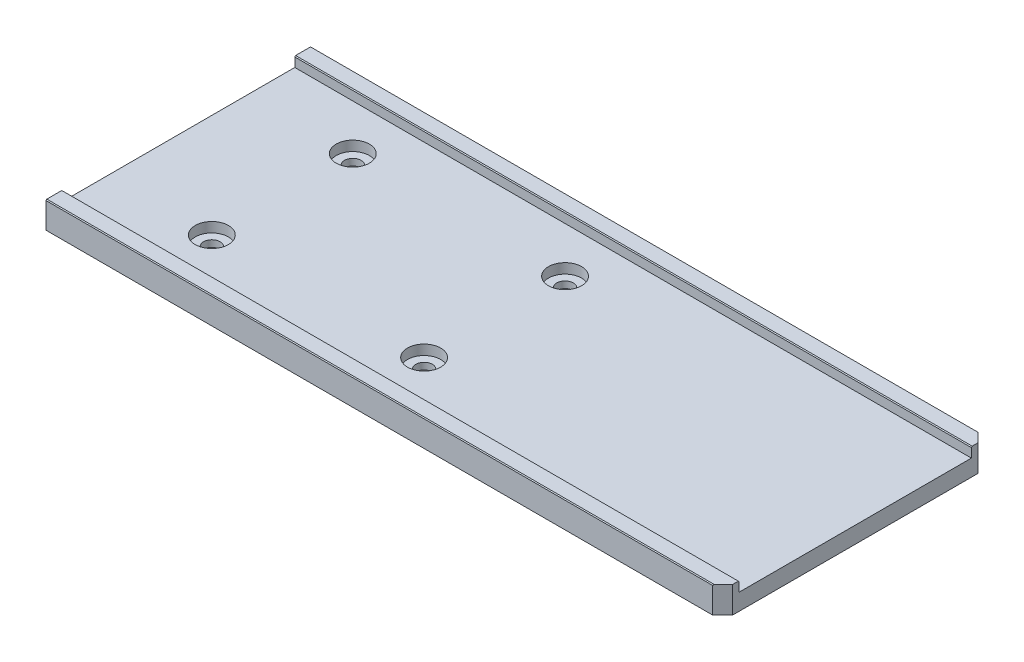
from build123d import *

# Parameters (mm, degrees)
SKETCH1_W           = 204
SKETCH1_H           = 80
BOSS_EXTRUDE1_DEPTH = 8
SKETCH2_W           = 204
SKETCH2_H           = 70
CUT_EXTRUDE1_DEPTH  = 3
SKETCH3_R           = 5
CUT_EXTRUDE2_DEPTH  = 3
SKETCH4_R           = 2.5
CUT_EXTRUDE3_DEPTH  = 3
CHAMFER1_SIZE       = 3
CHAMFER2_SIZE       = 0.25


with BuildPart() as part:
    # Sketch1 → Boss-Extrude1 (new body)
    with BuildSketch(Plane(origin=(0, 0, 0), x_dir=(1, 0, 0), z_dir=(0, 1, 0))):
        with Locations((102, 40)):
            Rectangle(SKETCH1_W, SKETCH1_H)
    extrude(amount=BOSS_EXTRUDE1_DEPTH)

    # Sketch2 → Cut-Extrude1 (cut)
    with BuildSketch(Plane(origin=(0, 8, 0), x_dir=(1, 0, 0), z_dir=(0, 1, 0))):
        with Locations((102, 40)):
            Rectangle(SKETCH2_W, SKETCH2_H)
    extrude(amount=-CUT_EXTRUDE1_DEPTH, mode=Mode.SUBTRACT)

    # Sketch3 → Cut-Extrude2 (cut)
    with BuildSketch(Plane(origin=(0, 5, 0), x_dir=(1, 0, 0), z_dir=(0, 1, 0))):
        with Locations((31.247103349, 61.25)):
            Circle(SKETCH3_R)
        with Locations((95.247103349, 61.25)):
            Circle(SKETCH3_R)
        with Locations((31.247103349, 18.75)):
            Circle(SKETCH3_R)
        with Locations((95.247103349, 18.75)):
            Circle(SKETCH3_R)
    extrude(amount=-CUT_EXTRUDE2_DEPTH, mode=Mode.SUBTRACT)

    # Sketch4 → Cut-Extrude3 (cut, through all)
    with BuildSketch(Plane(origin=(0, 2, 0), x_dir=(1, 0, 0), z_dir=(0, 1, 0))):
        with Locations((31.247103349, 61.25)):
            Circle(SKETCH4_R)
        with Locations((95.247103349, 61.25)):
            Circle(SKETCH4_R)
        with Locations((95.247103349, 18.75)):
            Circle(SKETCH4_R)
        with Locations((31.247103349, 18.75)):
            Circle(SKETCH4_R)
    extrude(amount=-CUT_EXTRUDE3_DEPTH, mode=Mode.SUBTRACT)

    # Chamfer1
    chamfer1_edges = [part.edges().sort_by_distance(p)[0] for p in [
        (204, 4, -80),
        (204, 4, 0),
    ]]
    chamfer(chamfer1_edges, length=CHAMFER1_SIZE)

    # Chamfer2
    chamfer2_edges = [part.edges().sort_by_distance(p)[0] for p in [
        (102, 8, -5),
        (102, 8, -75),
        (100.5, 8, -80),
        (100.5, 8, 0),
    ]]
    chamfer(chamfer2_edges, length=CHAMFER2_SIZE)


solid = part.part
